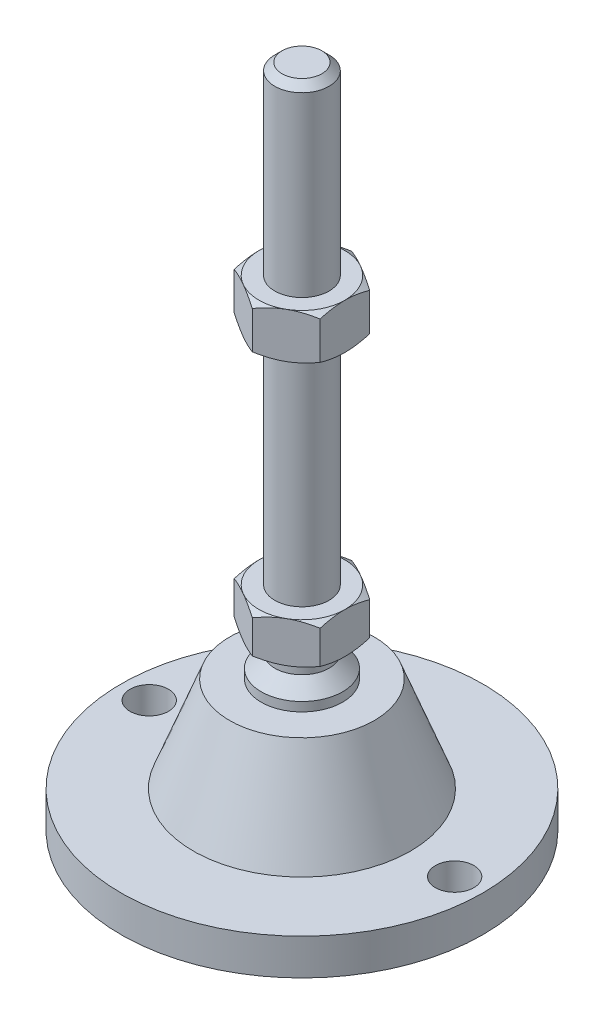
from build123d import *

# Parameters (mm, degrees)
EXTRUDE_1_DEPTH     = 9
EXTRUDE_2_DEPTH     = 10
SKETCH_5_R          = 4.25
CUT_EXTRUDE_1_DEPTH = 9


with BuildPart() as part:
    # Эскиз1 → Повернуть1 (revolve)
    with BuildSketch(Plane.XY, mode=Mode.PRIVATE) as revolve_1_sk:
        Polygon((0, 0), (-40, 0), (-40, 8), (-24, 8), (-16, 29), (-9, 29), (-9, 31), (-6, 34), (-6, 38), (-6, 47), (-6, 145.4), (-4.4, 147), (0, 147), align=None)
    revolve(revolve_1_sk.sketch.rotate(Axis((0, 0, 0), (0, 1, 0)), 180), axis=Axis((0, 0, 0), (0, 1, 0)))  # turned: the seam where the file's is

    # Эскиз2 → Бобышка-Вытянуть1 (add)
    with BuildSketch(Plane(origin=(0, 38, 0), x_dir=(1, 0, 0), z_dir=(0, 1, 0))):
        Polygon((0, 10.969655115), (-9.5, 5.484827557), (-9.5, -5.484827557), (0, -10.969655115), (9.5, -5.484827557), (9.5, 5.484827557), align=None)
    extrude(amount=EXTRUDE_1_DEPTH)

    # Эскиз3 → Бобышка-Вытянуть2 (add)
    with BuildSketch(Plane(origin=(0, 96.2, 0), x_dir=(1, 0, 0), z_dir=(0, 1, 0))):
        Polygon((9.5, 5.484827557), (0, 10.969655115), (-9.5, 5.484827557), (-9.5, -5.484827557), (0, -10.969655115), (9.5, -5.484827557), align=None)
    extrude(amount=EXTRUDE_2_DEPTH)

    # Эскиз4 → Вырез-Повернуть2 (revolve, cut)
    with BuildSketch(Plane.XY, mode=Mode.PRIVATE) as cut_revolve_2_sk:
        Polygon((-18.160254038, 106.2), (-9.5, 106.2), (-18.160254038, 101.2), align=None)
        Polygon((-18.160254038, 96.2), (-18.160254038, 101.2), (-9.5, 96.2), align=None)
        Polygon((-17.294228634, 47), (-17.294228634, 42.5), (-9.5, 47), align=None)
        Polygon((-17.294228634, 42.5), (-17.294228634, 38), (-9.5, 38), align=None)
    revolve(cut_revolve_2_sk.sketch.rotate(Axis((0, 147, 0), (0, -1, 0)), 180), axis=Axis((0, 147, 0), (0, -1, 0)), mode=Mode.SUBTRACT)  # turned: the seam where the file's is

    # Эскиз5 → Вырез-Вытянуть1 (cut, through all)
    with BuildSketch(Plane(origin=(0, 8, 0), x_dir=(1, 0, 0), z_dir=(0, 1, 0))):
        with Locations(Location((-33.75, 0, 0), (0, 0, 180))):  # turned: the seam where the file's is
            Circle(SKETCH_5_R)
        with Locations(Location((33.75, 0, 0), (0, 0, 180))):  # turned: the seam where the file's is
            Circle(SKETCH_5_R)
    extrude(amount=-CUT_EXTRUDE_1_DEPTH, mode=Mode.SUBTRACT)


solid = part.part
